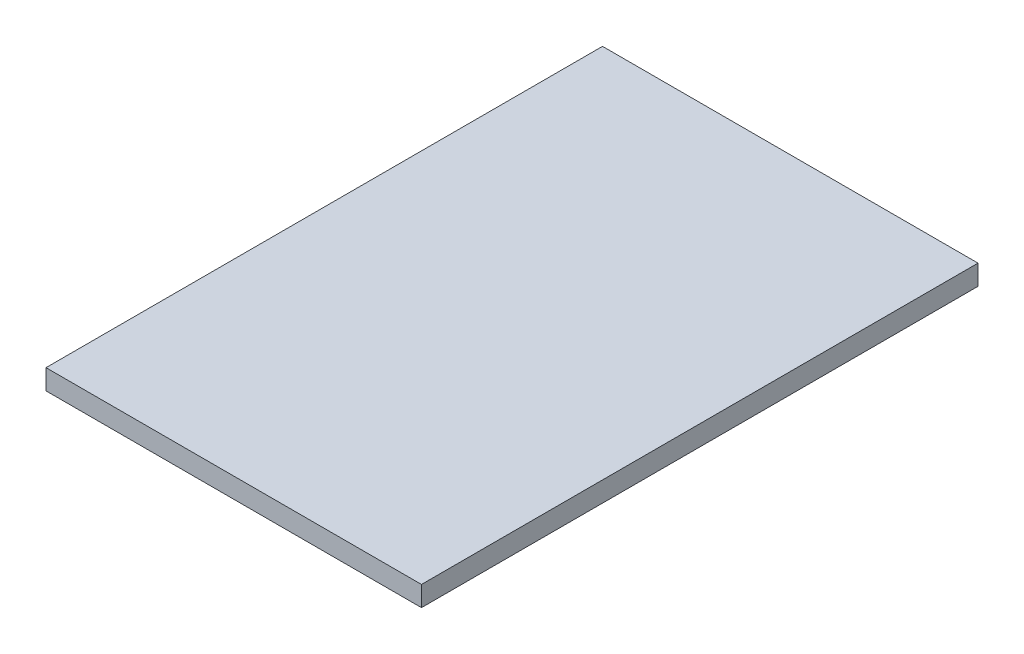
from build123d import *

# Parameters (mm, degrees)
SKETCH1_W           = 177.8
SKETCH1_H           = 263.525
BOSS_EXTRUDE1_DEPTH = 9.525


with BuildPart() as part:
    # Sketch1 → Boss-Extrude1 (new body)
    with BuildSketch(Plane(origin=(0, 0, 0), x_dir=(1, 0, 0), z_dir=(0, 1, 0))):
        Rectangle(SKETCH1_W, SKETCH1_H)
    extrude(amount=BOSS_EXTRUDE1_DEPTH)


solid = part.part
